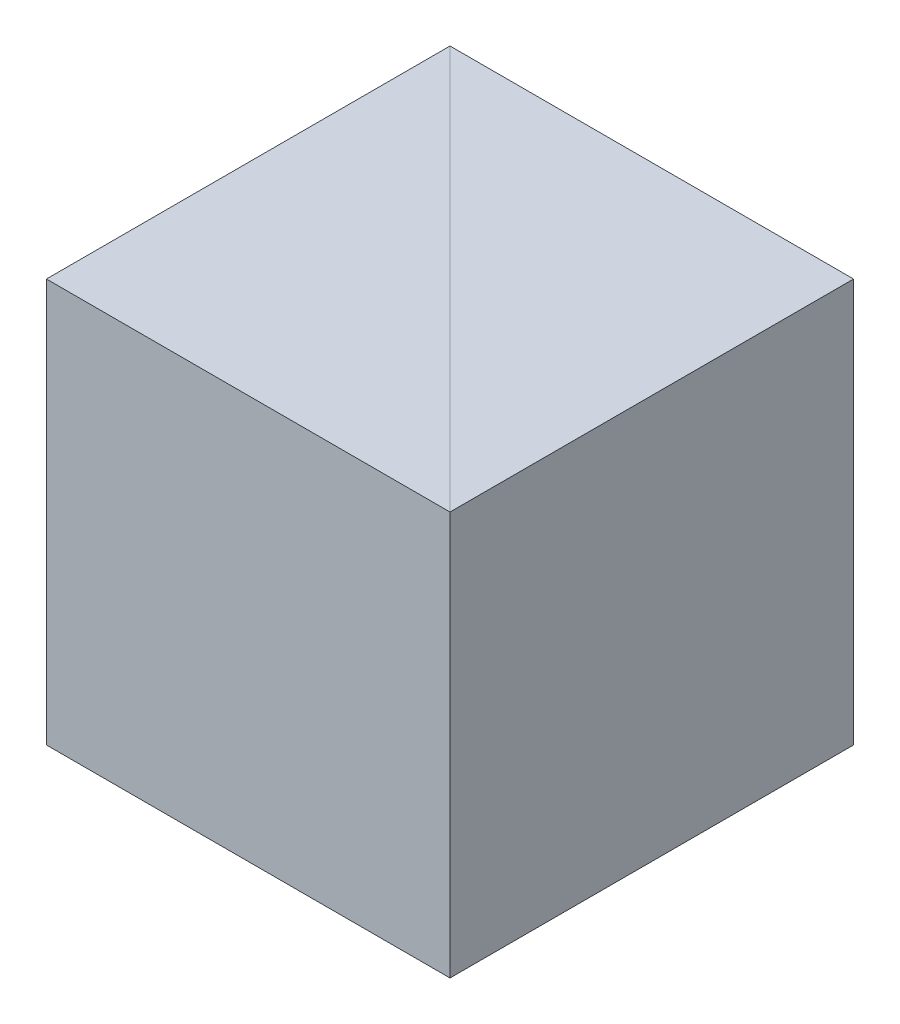
from build123d import *

# Parameters (mm, degrees)
EXTRUDE_1_DEPTH = 12.5
EXTRUDE_2_DEPTH = 12.5


with BuildPart() as part:
    # 草图1 → 凸台-拉伸1 (new body)
    with BuildSketch(Plane(origin=(0, 0, 0), x_dir=(1, 0, 0), z_dir=(0, 1, 0))):
        Polygon((0, 0), (0, 12.5), (-12.5, 12.5), align=None)
    extrude(amount=EXTRUDE_1_DEPTH)


with BuildPart() as body_2:
    # 草图2 → 凸台-拉伸2 (new body)
    with BuildSketch(Plane.XZ):
        Polygon((-12.5, -12.5), (-12.5, 0), (0, 0), align=None)
    extrude(amount=-EXTRUDE_2_DEPTH)


solid = Compound([part.part, body_2.part])
